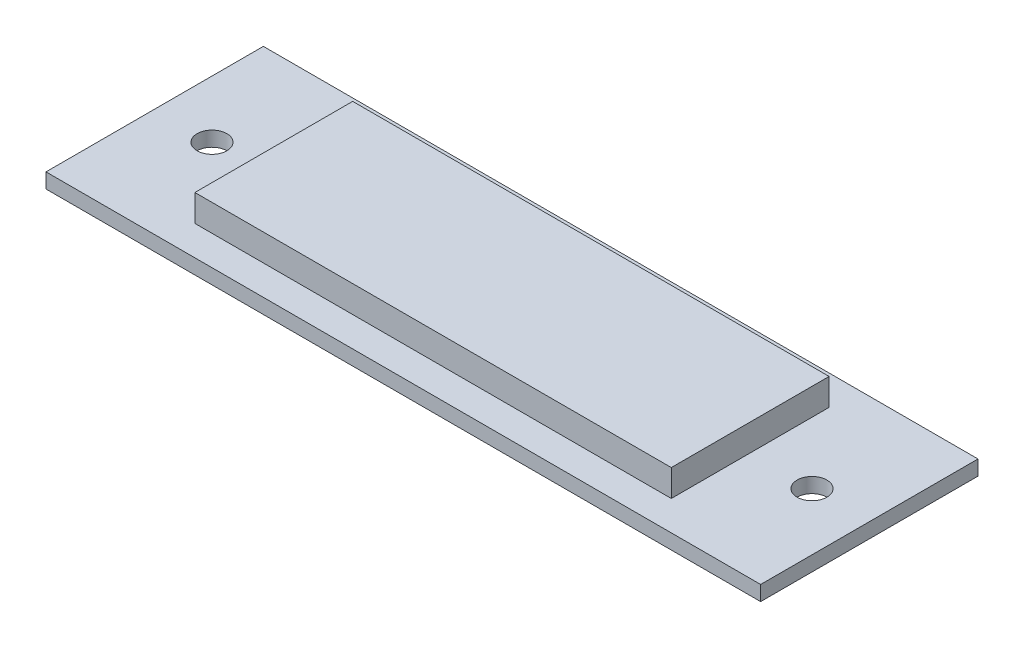
from build123d import *

# Parameters (mm, degrees)
SKETCH1_W                = 80
SKETCH1_H                = 26.5
BOSS_EXTRUDE1_DEPTH      = 7
SKETCH5_W                = 80
SKETCH5_H                = 2.5
BOSS_EXTRUDE5_DEPTH      = 5
BOSS_EXTRUDE5_DEPTH_BACK = 31.5
SKETCH6_W                = 36.5
SKETCH6_H                = 2.5
BOSS_EXTRUDE6_DEPTH      = 20
BOSS_EXTRUDE6_DEPTH_BACK = 100
F_5_0MM_DOWEL_HOLE1_D    = 5


with BuildPart() as part:
    # Sketch1 → Boss-Extrude1 (new body)
    with BuildSketch(Plane(origin=(0, 0, 0), x_dir=(1, 0, 0), z_dir=(0, 1, 0))):
        with Locations((40, 13.25)):
            Rectangle(SKETCH1_W, SKETCH1_H)
    extrude(amount=BOSS_EXTRUDE1_DEPTH)

    # Sketch5 → Boss-Extrude5 (add, two sides)
    with BuildSketch(Plane.XY) as boss_extrude5_sk:
        with Locations((40, 1.25)):
            Rectangle(SKETCH5_W, SKETCH5_H)
    extrude(amount=BOSS_EXTRUDE5_DEPTH)
    extrude(boss_extrude5_sk.sketch, amount=-BOSS_EXTRUDE5_DEPTH_BACK)

    # Sketch6 → Boss-Extrude6 (add, two sides)
    with BuildSketch(Plane(origin=(80, 0, 0), x_dir=(0, 0, -1), z_dir=(1, 0, 0))) as boss_extrude6_sk:
        with Locations((13.25, 1.25)):
            Rectangle(SKETCH6_W, SKETCH6_H)
    extrude(amount=BOSS_EXTRUDE6_DEPTH)
    extrude(boss_extrude6_sk.sketch, amount=-BOSS_EXTRUDE6_DEPTH_BACK)

    # Ø5.0mm Dowel Hole1 (through all)
    with Locations(Plane(origin=(0, 2.5, 0), x_dir=(1, 0, 0), z_dir=(0, 1, 0))):
        with Locations((-10.375, 13.25), (90.375, 13.25)):
            Hole(F_5_0MM_DOWEL_HOLE1_D / 2)


solid = part.part
